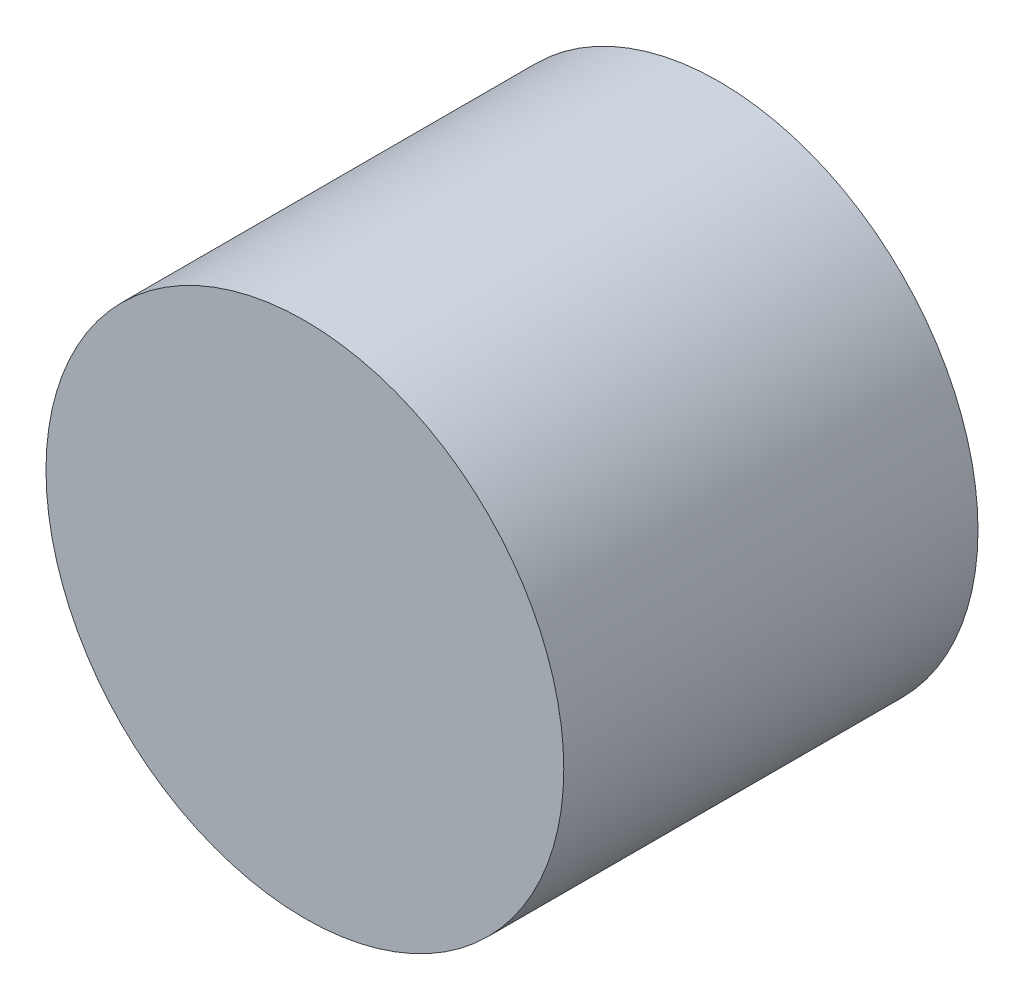
from build123d import *

# Parameters (mm, degrees)
SKETCH1_R           = 6.25
BOSS_EXTRUDE1_DEPTH = 10
SKETCH1_3_R         = 5.25
CUT_EXTRUDE1_DEPTH  = 8


with BuildPart() as part:
    # Sketch1 → Boss-Extrude1 (new body)
    with BuildSketch(Plane.XY):
        Circle(SKETCH1_R)
    extrude(amount=BOSS_EXTRUDE1_DEPTH)

    # Sketch1_3 → Cut-Extrude1 (cut)
    with BuildSketch(Plane.XY):
        Circle(SKETCH1_3_R)
    extrude(amount=CUT_EXTRUDE1_DEPTH, mode=Mode.SUBTRACT)


solid = part.part
